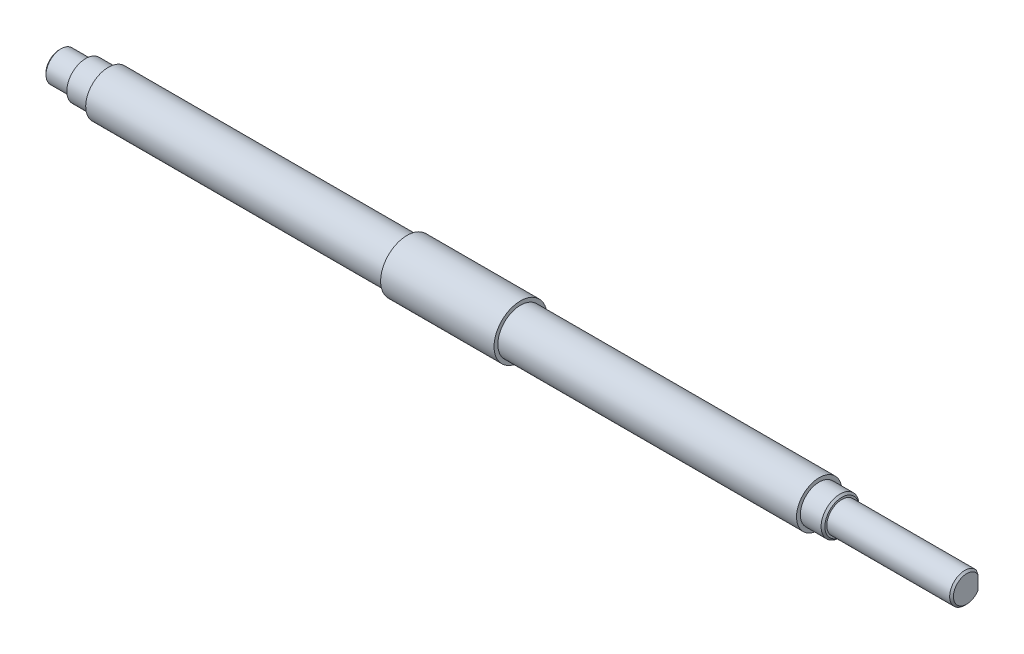
from build123d import *

# Parameters (mm, degrees)
SKETCH_2_W          = 25.545670962
SKETCH_2_H          = 18.659121507
CUT_EXTRUDE_1_DEPTH = 10
CHAMFER_1_SIZE      = 0.5


with BuildPart() as part:
    # 草图1 → 旋转1 (revolve)
    with BuildSketch(Plane.XY):
        Polygon((-107, 0), (-107, 4), (-100, 4), (-100, 5), (-94, 5), (-94, 6), (-15, 6), (-15, 7), (15, 7), (15, 6), (94, 6), (94, 5), (100, 5), (100, 4), (133, 4), (133, 0), align=None)
    revolve(axis=Axis((-107, 0, 0), (1, 0, 0)))

    # 草图2 → 切除-拉伸1 (cut)
    with BuildSketch(Plane.XY.offset(-3)):
        with Locations((125.772835481, -0.110098382)):
            Rectangle(SKETCH_2_W, SKETCH_2_H)
    extrude(amount=-CUT_EXTRUDE_1_DEPTH, mode=Mode.SUBTRACT)

    # 倒角1
    chamfer_1_edges = [part.edges().sort_by_distance(p)[0] for p in [
        (100, -5, 0),
        (-107, -4, 0),
        (133, -1.645751311, 3.645751311),
    ]]
    chamfer(chamfer_1_edges, length=CHAMFER_1_SIZE)


solid = part.part
